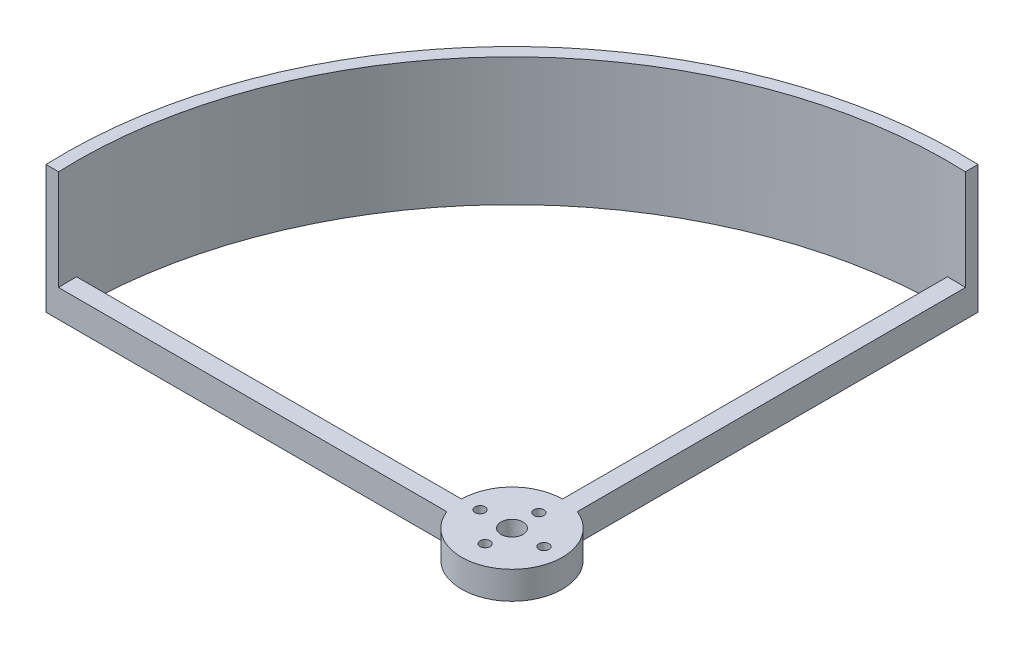
from build123d import *

# Parameters (mm, degrees)
SKETCH1_R           = 15
BOSS_EXTRUDE2_DEPTH = 8.255
BOSS_EXTRUDE3_DEPTH = 8.255
BOSS_EXTRUDE4_DEPTH = 38.1
SKETCH5_R           = 1.500000048
SKETCH5_R_2         = 1.5
SKETCH5_R_3         = 3.249999977
CUT_EXTRUDE3_DEPTH  = 63.5


with BuildPart() as part:
    # Sketch1 → Boss-Extrude2 (new body)
    with BuildSketch(Plane(origin=(0, 0, 0), x_dir=(1, 0, 0), z_dir=(0, 1, 0))):
        Circle(SKETCH1_R)
    extrude(amount=BOSS_EXTRUDE2_DEPTH)

    # Sketch1_6 → Boss-Extrude3 (add)
    with BuildSketch(Plane(origin=(0, 0, 0), x_dir=(1, 0, 0), z_dir=(0, 1, 0))):
        with BuildLine():
            ThreePointArc((5.451587957, 129.488518037), (2.726397307, 129.574545619), (0, 129.603225711))
            Line((0, 129.603225711), (0, 15))
            ThreePointArc((0, 15), (2.773622889, 14.741336984), (5.451587957, 13.974268809))
            Line((5.451587957, 13.974268809), (5.451587957, 129.488518037))
        make_face()
        with BuildLine():
            Line((-15, 0), (-129.603225711, 0))
            ThreePointArc((-129.603225711, 0), (-129.574545619, -2.726397307), (-129.488518037, -5.451587957))
            Line((-129.488518037, -5.451587957), (-13.974268809, -5.451587957))
            ThreePointArc((-13.974268809, -5.451587957), (-14.741336984, -2.773622889), (-15, 0))
        make_face()
    extrude(amount=BOSS_EXTRUDE3_DEPTH)

    # Sketch1_7 → Boss-Extrude4 (add)
    with BuildSketch(Plane(origin=(0, 0, 0), x_dir=(1, 0, 0), z_dir=(0, 1, 0))):
        with BuildLine():
            ThreePointArc((-129.603225711, 0), (-91.643319764, 91.643319764), (0, 129.603225711))
            ThreePointArc((0, 129.603225711), (2.726397307, 129.574545619), (5.451587957, 129.488518037))
            Line((5.451587957, 129.488518037), (5.451587957, 133.238518037))
            ThreePointArc((5.451587957, 133.238518037), (-94.292689271, 94.292689271), (-133.238518037, -5.451587957))
            Line((-133.238518037, -5.451587957), (-129.488518037, -5.451587957))
            ThreePointArc((-129.488518037, -5.451587957), (-129.574545619, -2.726397307), (-129.603225711, 0))
        make_face()
    extrude(amount=BOSS_EXTRUDE4_DEPTH)

    # Sketch5 → Cut-Extrude3 (cut)
    with BuildSketch(Plane(origin=(0, 8.255, 0), x_dir=(1, 0, 0), z_dir=(0, 1, 0))):
        with Locations((-9.5, 0)):
            Circle(SKETCH5_R)
        with Locations((0, 8)):
            Circle(SKETCH5_R_2)
        with Locations((0, -8)):
            Circle(SKETCH5_R_2)
        with Locations((9.5, 0)):
            Circle(SKETCH5_R)
        Circle(SKETCH5_R_3)
    extrude(amount=-CUT_EXTRUDE3_DEPTH, mode=Mode.SUBTRACT)


solid = part.part
